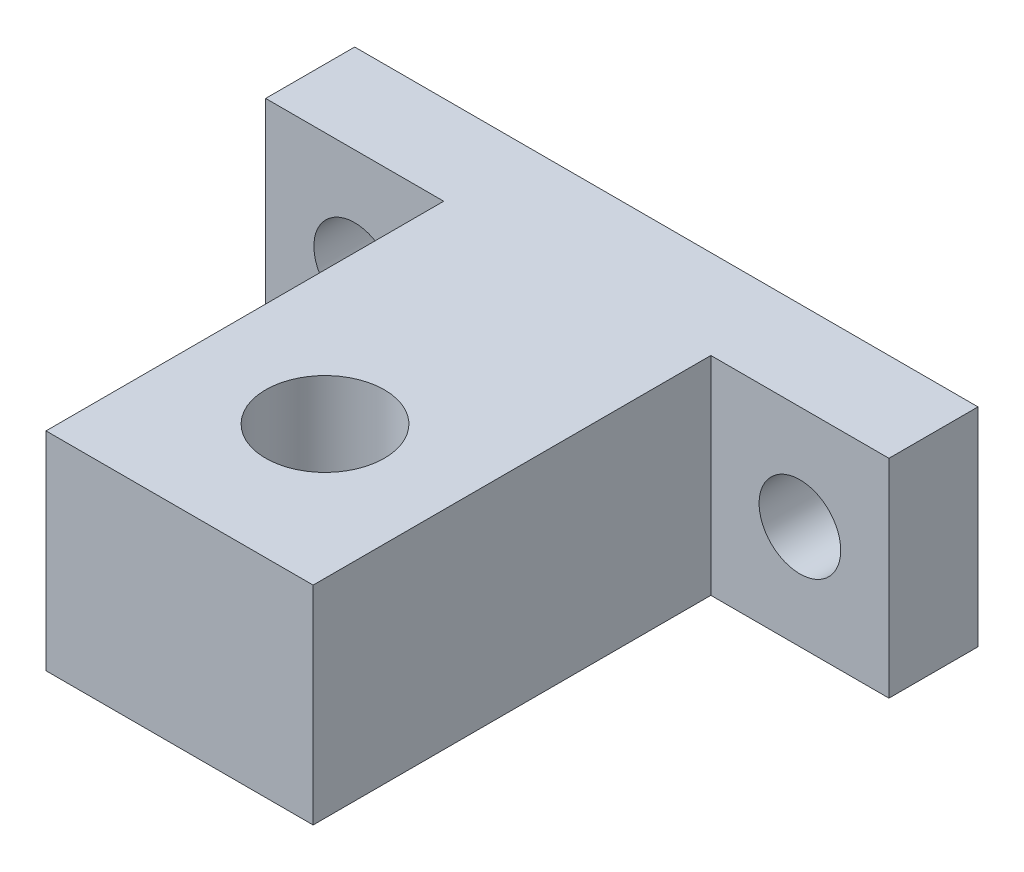
from build123d import *

# Parameters (mm, degrees)
PROFILE_EXTRUDE_DEPTH   = 14
BORE_SKETCH_R           = 4
BORE_CUT_DEPTH          = 15
MOUNTING_HOLE_SKETCH_R  = 2.75
MOUNTING_HOLE_CUT_DEPTH = 7


with BuildPart() as part:
    # Profile Sketch → Profile Extrude (new body)
    with BuildSketch(Plane(origin=(0, 0, 0), x_dir=(1, 0, 0), z_dir=(0, 1, 0))):
        Polygon((9, -3), (21, -3), (21, 3), (-21, 3), (-21, -3), (-9, -3), (-9, -29.8), (9, -29.8), align=None)
    extrude(amount=PROFILE_EXTRUDE_DEPTH)

    # Bore Sketch → Bore Cut (cut, through all)
    with BuildSketch(Plane.XZ):
        with Locations((0, 20)):
            Circle(BORE_SKETCH_R)
    extrude(amount=-BORE_CUT_DEPTH, mode=Mode.SUBTRACT)

    # Mounting Hole Sketch → Mounting Hole Cut (cut, through all)
    with BuildSketch(Plane.XY.offset(3)):
        with Locations((15, 7)):
            Circle(MOUNTING_HOLE_SKETCH_R)
        with Locations((-15, 7)):
            Circle(MOUNTING_HOLE_SKETCH_R)
    extrude(amount=-MOUNTING_HOLE_CUT_DEPTH, mode=Mode.SUBTRACT)


solid = part.part
